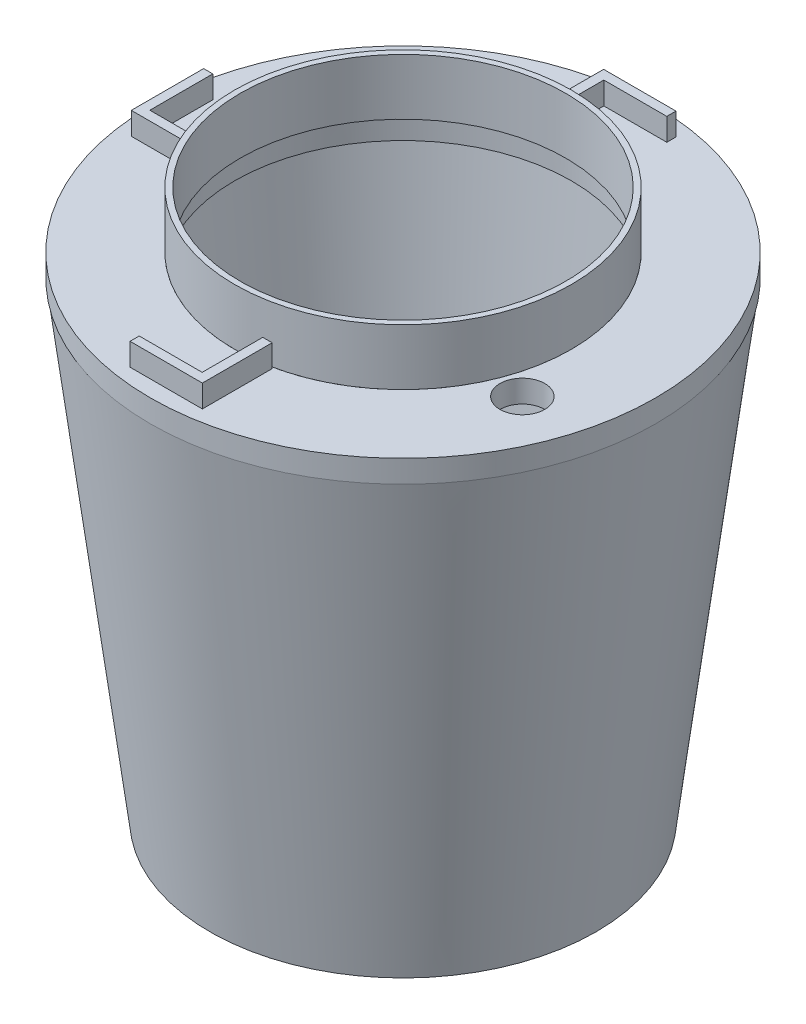
from build123d import *

# Parameters (mm, degrees)
SKETCH8_R               = 449.913599191
SKETCH8_R_2             = 300
BOSS_EXTRUDE5_DEPTH     = 40
SKETCH9_R               = 300
SKETCH9_R_2             = 290
BOSS_EXTRUDE6_DEPTH     = 100
SKETCH11_R              = 40
CUT_EXTRUDE2_DEPTH      = 75
CUT_EXTRUDE2_DEPTH_BACK = 109
BOSS_EXTRUDE13_DEPTH    = 40


with BuildPart() as part:
    # Sketch2 → Revolve2 (revolve)
    with BuildSketch(Plane.XY):
        Polygon((300, -346.365021048), (400.000001225, 453.634978952), (449.613895127, 447.433242138), (344.139110927, -396.365021124), (0, -396.365021124), (0, -346.365021048), align=None)
    revolve(axis=Axis((0, -396.365021124, 0), (0, 1, 0)))

    # Sketch8 → Boss-Extrude5 (add)
    with BuildSketch(Plane(origin=(0, 440, 0), x_dir=(-1, 0, 0), z_dir=(0, -1, 0))):
        Circle(SKETCH8_R)
        Circle(SKETCH8_R_2, mode=Mode.SUBTRACT)
    extrude(amount=-BOSS_EXTRUDE5_DEPTH)

    # Sketch11 → Cut-Extrude2 (cut, two sides)
    with BuildSketch(Plane(origin=(0, 440, 0), x_dir=(-1, 0, 0), z_dir=(0, -1, 0))) as cut_extrude2_sk:
        with Locations((-329, -116.390796004)):
            Circle(SKETCH11_R)
    extrude(amount=CUT_EXTRUDE2_DEPTH, mode=Mode.SUBTRACT)
    extrude(cut_extrude2_sk.sketch, amount=-CUT_EXTRUDE2_DEPTH_BACK, mode=Mode.SUBTRACT)

    # Sketch12 → Boss-Extrude13 (add)
    with BuildSketch(Plane(origin=(0, 480, 0), x_dir=(1, 0, 0), z_dir=(0, 1, 0))):
        Polygon((-420.640420646, 65.560892628), (-420.640420646, -63.300257476), (-404.30487033, -63.300257476), (-300, -63.300257476), (-296.359650017, -63.300257476), (-296.359650017, -46.593538627), (-300, -46.593538627), (-404.30487033, -46.593538627), (-404.30487033, 65.560892628), align=None)
        Polygon((65.560892628, 420.640420646), (65.560892628, 404.30487033), (-46.593538627, 404.30487033), (-46.593538627, 300), (-46.593538627, 296.359650017), (-63.300257476, 296.359650017), (-63.300257476, 300), (-63.300257476, 404.30487033), (-63.300257476, 420.640420646), align=None)
        Polygon((46.593538627, -300), (46.593538627, -296.359650017), (63.300257476, -296.359650017), (63.300257476, -300), (63.300257476, -404.30487033), (63.300257476, -420.640420646), (-65.560892628, -420.640420646), (-65.560892628, -404.30487033), (46.593538627, -404.30487033), align=None)
    extrude(amount=BOSS_EXTRUDE13_DEPTH)


with BuildPart() as body_2:
    # Sketch9 → Boss-Extrude6 (new body)
    with BuildSketch(Plane(origin=(0, 480, 0), x_dir=(1, 0, 0), z_dir=(0, 1, 0))):
        Circle(SKETCH9_R)
        Circle(SKETCH9_R_2, mode=Mode.SUBTRACT)
    extrude(amount=BOSS_EXTRUDE6_DEPTH)


solid = Compound([part.part, body_2.part])
